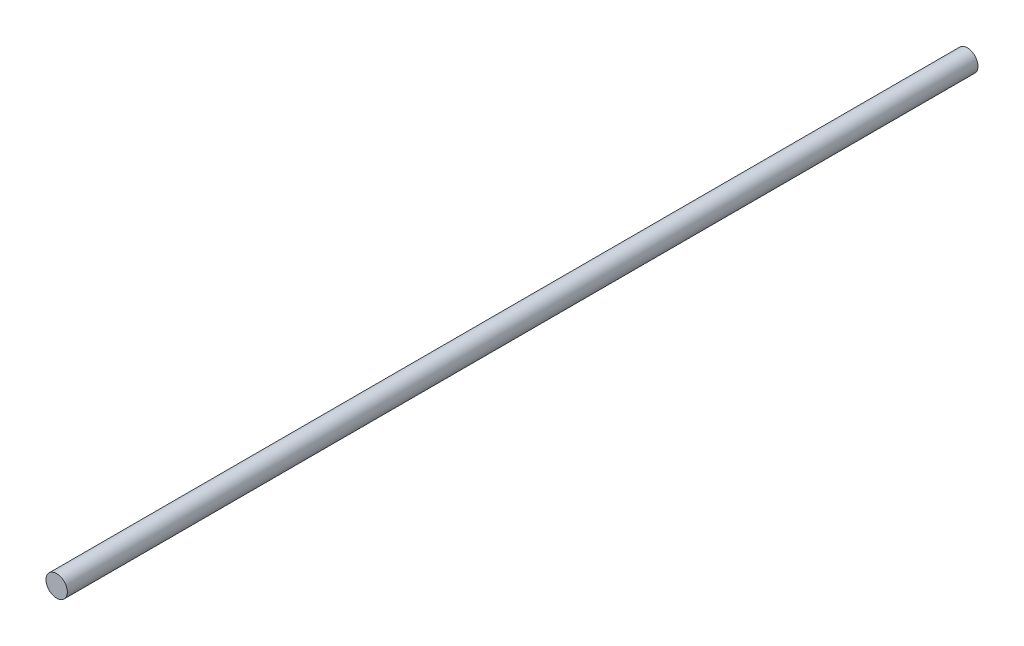
from build123d import *

# Parameters (mm, degrees)
SKETCH1_R           = 2.38125
BOSS_EXTRUDE1_DEPTH = 203.2


with BuildPart() as part:
    # Sketch1 → Boss-Extrude1 (new body)
    with BuildSketch(Plane.XY):
        Circle(SKETCH1_R)
    extrude(amount=BOSS_EXTRUDE1_DEPTH)


solid = part.part
